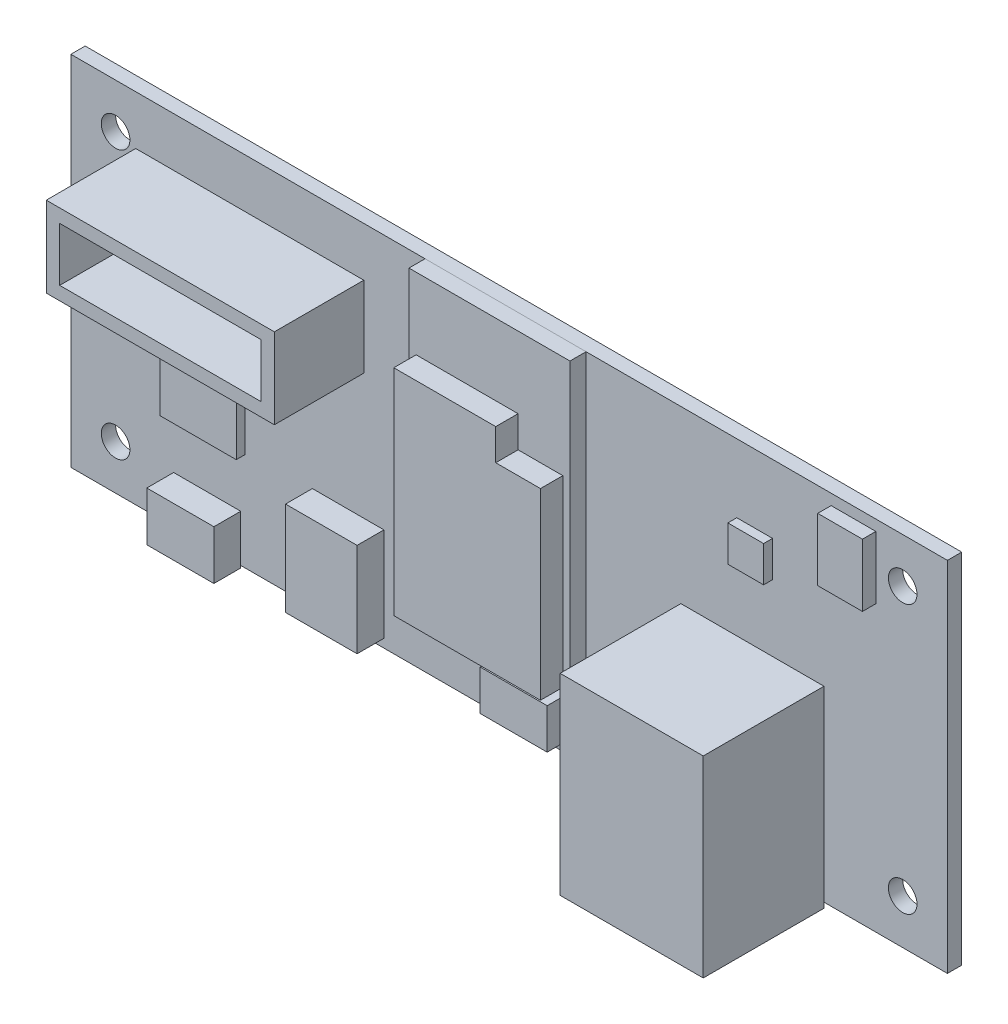
from build123d import *

# Parameters (mm, degrees)
SKETCH1_W               = 98
SKETCH1_H               = 40
BOSS_EXTRUDE1_DEPTH     = 1.6
SKETCH2_R               = 1.6
CUT_EXTRUDE1_DEPTH      = 1
CUT_EXTRUDE1_DEPTH_BACK = 2.6
SKETCH3_W               = 25.5
SKETCH3_H               = 9
BOSS_EXTRUDE2_DEPTH     = 10
SHELL1_T                = -1.5
SKETCH4_W               = 8.5
SKETCH4_H               = 8.5
BOSS_EXTRUDE3_DEPTH     = 1
SKETCH5_W               = 7.5
SKETCH5_H               = 5.5
BOSS_EXTRUDE4_DEPTH     = 3
SKETCH6_W               = 8
SKETCH6_H               = 10.5
BOSS_EXTRUDE5_DEPTH     = 3
SKETCH7_W               = 18
SKETCH7_H               = 32
BOSS_EXTRUDE6_DEPTH     = 1.8
BOSS_EXTRUDE7_DEPTH     = 2.5
SKETCH9_W               = 7.5
SKETCH9_H               = 4.5
BOSS_EXTRUDE8_DEPTH     = 3.5
SKETCH10_W              = 16
SKETCH10_H              = 21.5
BOSS_EXTRUDE9_DEPTH     = 13.5
SKETCH11_W              = 12
SKETCH11_H              = 7.1
SKETCH11_W_2            = 4
SKETCH11_H_2            = 1
CUT_EXTRUDE2_DEPTH      = 10
SKETCH12_W              = 4
SKETCH12_H              = 4
BOSS_EXTRUDE10_DEPTH    = 1
SKETCH13_W              = 5
SKETCH13_H              = 7
BOSS_EXTRUDE11_DEPTH    = 1.5


with BuildPart() as part:
    # Sketch1 → Boss-Extrude1 (new body)
    with BuildSketch(Plane.XY):
        Rectangle(SKETCH1_W, SKETCH1_H)
    extrude(amount=BOSS_EXTRUDE1_DEPTH)

    # Sketch2 → Cut-Extrude1 (cut, two sides)
    with BuildSketch(Plane.XY.offset(1.6)) as cut_extrude1_sk:
        with Locations((-44, -15)):
            Circle(SKETCH2_R)
        with Locations((-44, 15)):
            Circle(SKETCH2_R)
        with Locations((44, 15)):
            Circle(SKETCH2_R)
        with Locations((44, -15)):
            Circle(SKETCH2_R)
    extrude(amount=CUT_EXTRUDE1_DEPTH, mode=Mode.SUBTRACT)
    extrude(cut_extrude1_sk.sketch, amount=-CUT_EXTRUDE1_DEPTH_BACK, mode=Mode.SUBTRACT)

    # Sketch9 → Boss-Extrude8 (add)
    with BuildSketch(Plane.XY.offset(1.6)):
        with Locations((4, -15.2)):
            Rectangle(SKETCH9_W, SKETCH9_H)
    extrude(amount=BOSS_EXTRUDE8_DEPTH)


with BuildPart() as body_2:
    # Sketch3 → Boss-Extrude2 (new body)
    with BuildSketch(Plane.XY.offset(1.6)):
        with Locations((-29, 10)):
            Rectangle(SKETCH3_W, SKETCH3_H)
    extrude(amount=BOSS_EXTRUDE2_DEPTH)

    # Shell1
    shell1_openings = [body_2.faces().sort_by_distance(p)[0] for p in [
        (-29, 10, 11.6),
    ]]
    offset(amount=SHELL1_T, openings=shell1_openings, kind=Kind.INTERSECTION)


with BuildPart() as body_3:
    # Sketch4 → Boss-Extrude3 (new body)
    with BuildSketch(Plane.XY.offset(1.6)):
        with Locations((-33.76, -4.76)):
            Rectangle(SKETCH4_W, SKETCH4_H)
    extrude(amount=BOSS_EXTRUDE3_DEPTH)


with BuildPart() as body_4:
    # Sketch5 → Boss-Extrude4 (new body)
    with BuildSketch(Plane.XY.offset(1.6)):
        with Locations((-33.76, -17.5)):
            Rectangle(SKETCH5_W, SKETCH5_H)
    extrude(amount=BOSS_EXTRUDE4_DEPTH)


with BuildPart() as body_5:
    # Sketch6 → Boss-Extrude5 (new body)
    with BuildSketch(Plane.XY.offset(1.6)):
        with Locations((-18, -13.8)):
            Rectangle(SKETCH6_W, SKETCH6_H)
    extrude(amount=BOSS_EXTRUDE5_DEPTH)


with BuildPart() as body_6:
    # Sketch7 → Boss-Extrude6 (new body)
    with BuildSketch(Plane.XY.offset(1.6)):
        with Locations((-0.4, 4)):
            Rectangle(SKETCH7_W, SKETCH7_H)
    extrude(amount=BOSS_EXTRUDE6_DEPTH)


with BuildPart() as body_7:
    # Sketch8 → Boss-Extrude7 (new body)
    with BuildSketch(Plane.XY.offset(3.4)):
        Polygon((-8.6, 12), (-8.6, -12), (7.8, -12), (7.8, 8.5), (2.8, 8.5), (2.8, 12), align=None)
    extrude(amount=BOSS_EXTRUDE7_DEPTH)


with BuildPart() as body_8:
    # Sketch10 → Boss-Extrude9 (new body)
    with BuildSketch(Plane.XY.offset(1.6)):
        with Locations((27.2, -9.84)):
            Rectangle(SKETCH10_W, SKETCH10_H)
    extrude(amount=BOSS_EXTRUDE9_DEPTH)

    # Sketch11 → Cut-Extrude2 (cut)
    with BuildSketch(Plane.XZ.offset(20.59)):
        with Locations((27.2, 9.05)):
            Rectangle(SKETCH11_W, SKETCH11_H)
        Polygon((30.2, 5.5), (24.2, 5.5), (24.2, 4.5), (25.2, 4.5), (29.2, 4.5), (30.2, 4.5), align=None)
        with Locations((27.2, 4)):
            Rectangle(SKETCH11_W_2, SKETCH11_H_2)
    extrude(amount=-CUT_EXTRUDE2_DEPTH, mode=Mode.SUBTRACT)


with BuildPart() as body_9:
    # Sketch12 → Boss-Extrude10 (new body)
    with BuildSketch(Plane.XY.offset(1.6)):
        with Locations((27.45, 10.35)):
            Rectangle(SKETCH12_W, SKETCH12_H)
    extrude(amount=BOSS_EXTRUDE10_DEPTH)


with BuildPart() as body_10:
    # Sketch13 → Boss-Extrude11 (new body)
    with BuildSketch(Plane.XY.offset(1.6)):
        with Locations((38.5, 15.3)):
            Rectangle(SKETCH13_W, SKETCH13_H)
    extrude(amount=BOSS_EXTRUDE11_DEPTH)


solid = Compound([part.part, body_2.part, body_3.part, body_4.part, body_5.part, body_6.part, body_7.part, body_8.part, body_9.part, body_10.part])
